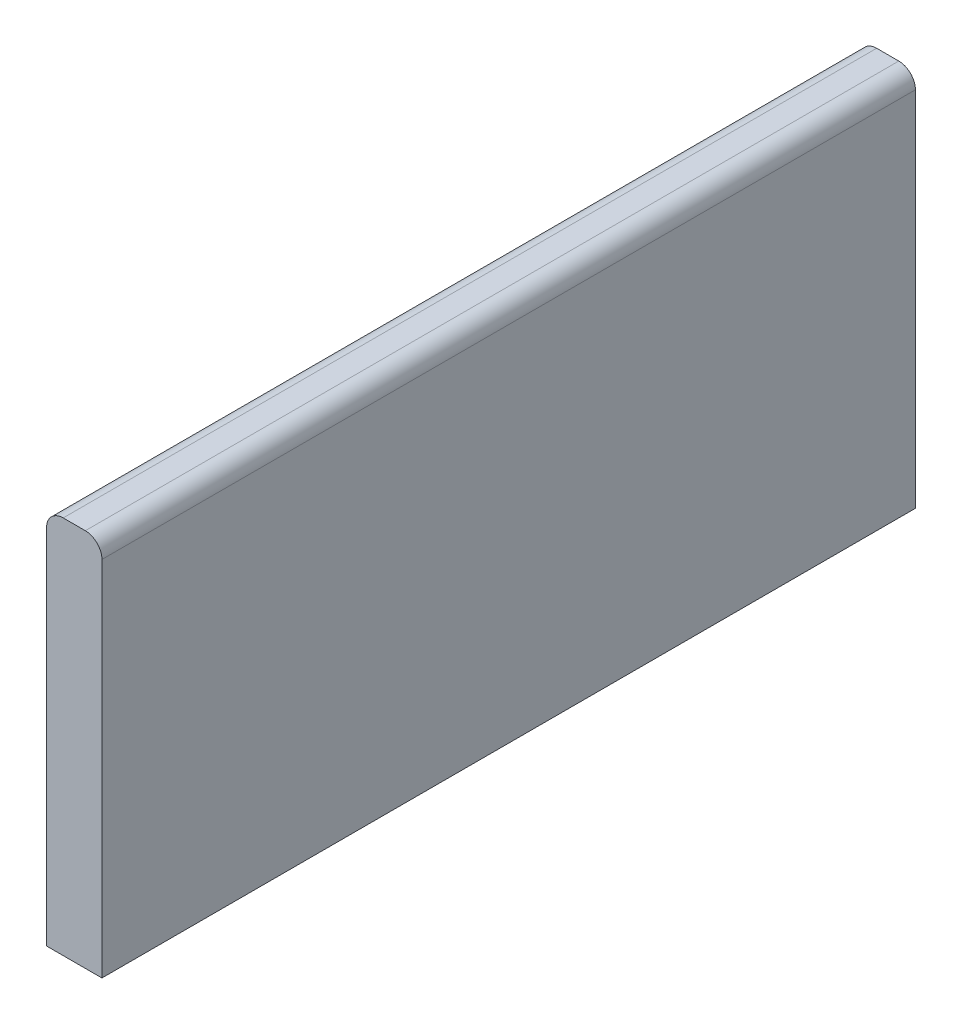
from build123d import *

# Parameters (mm, degrees)
ESQUISSE1_W        = 10
ESQUISSE1_H        = 68.5
BOSS_EXTRU_1_DEPTH = 147
CONG_1_R           = 3


with BuildPart() as part:
    # Esquisse1 → Boss.-Extru.1 (new body)
    with BuildSketch(Plane.XY):
        with Locations((-100, -39.25)):
            Rectangle(ESQUISSE1_W, ESQUISSE1_H)
    extrude(amount=BOSS_EXTRU_1_DEPTH)

    # Congé1
    cong_1_edges = [part.edges().sort_by_distance(p)[0] for p in [
        (-105, -5, 73.5),
        (-95, -5, 73.5),
    ]]
    fillet(cong_1_edges, radius=CONG_1_R)


solid = part.part
